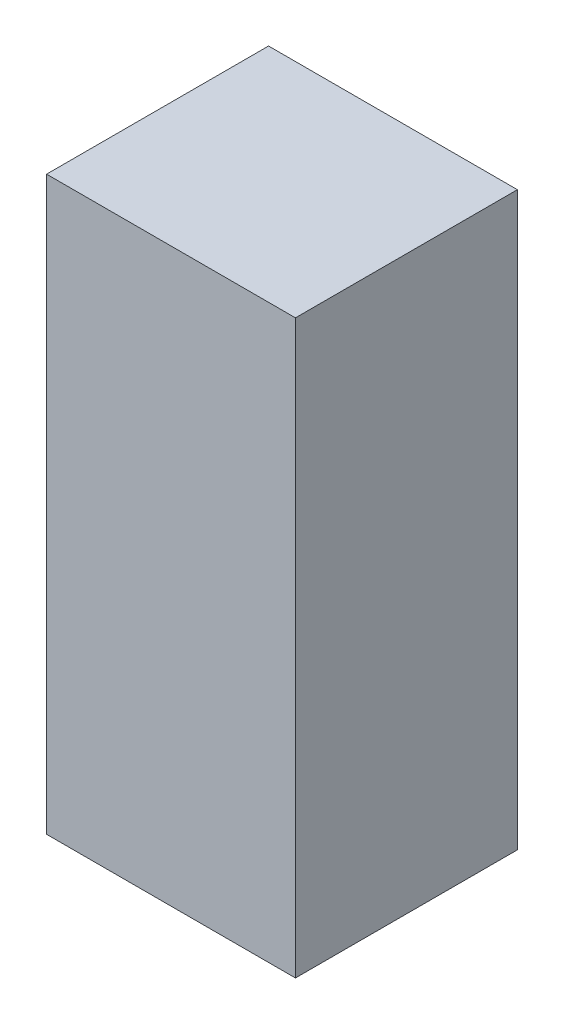
from build123d import *

# Parameters (mm, degrees)
CROQUIS1_W              = 37
CROQUIS1_H              = 33
SALIENTE_EXTRUIR1_DEPTH = 85


with BuildPart() as part:
    # Croquis1 → Saliente-Extruir1 (new body)
    with BuildSketch(Plane(origin=(0, 0, 0), x_dir=(1, 0, 0), z_dir=(0, 1, 0))):
        Rectangle(CROQUIS1_W, CROQUIS1_H)
    extrude(amount=SALIENTE_EXTRUIR1_DEPTH)


solid = part.part
